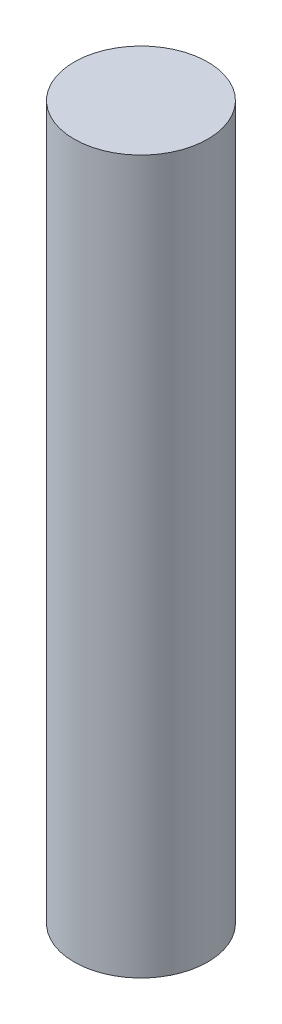
from build123d import *

# Parameters (mm, degrees)
SKETCH1_R           = 1.5
BOSS_EXTRUDE1_DEPTH = 8


with BuildPart() as part:
    # Sketch1 → Boss-Extrude1 (new body, symmetric)
    with BuildSketch(Plane(origin=(0, 0, 0), x_dir=(1, 0, 0), z_dir=(0, 1, 0))):
        Circle(SKETCH1_R)
    extrude(amount=BOSS_EXTRUDE1_DEPTH, both=True)


solid = part.part
